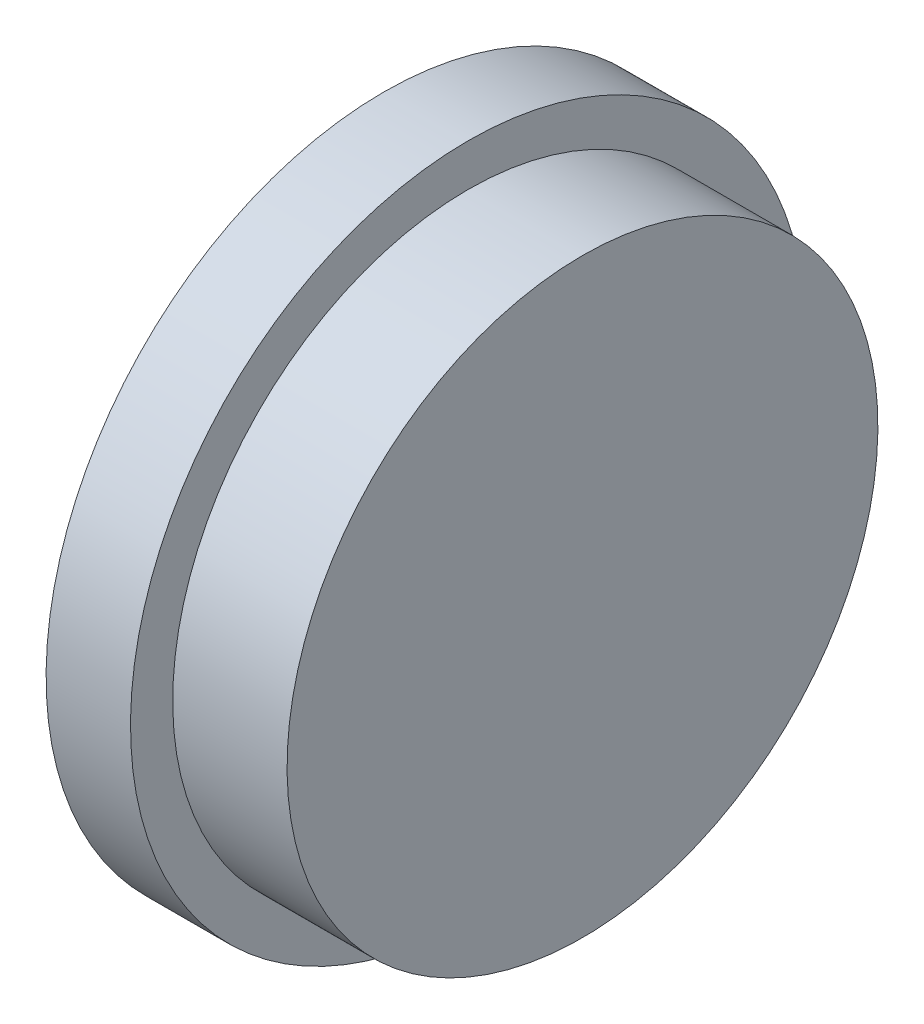
from build123d import *


with BuildPart() as part:
    # Esquisse1 → Révolution1 (revolve)
    with BuildSketch(Plane.XY):
        Polygon((0.870967742, 24), (6.870967742, 24), (6.870967742, 21), (15, 21), (15, 0), (13, 0), (13, 16), (0.870967742, 16), align=None)
    revolve(axis=Axis((13, 0, 0), (-1, 0, 0)))


solid = part.part
